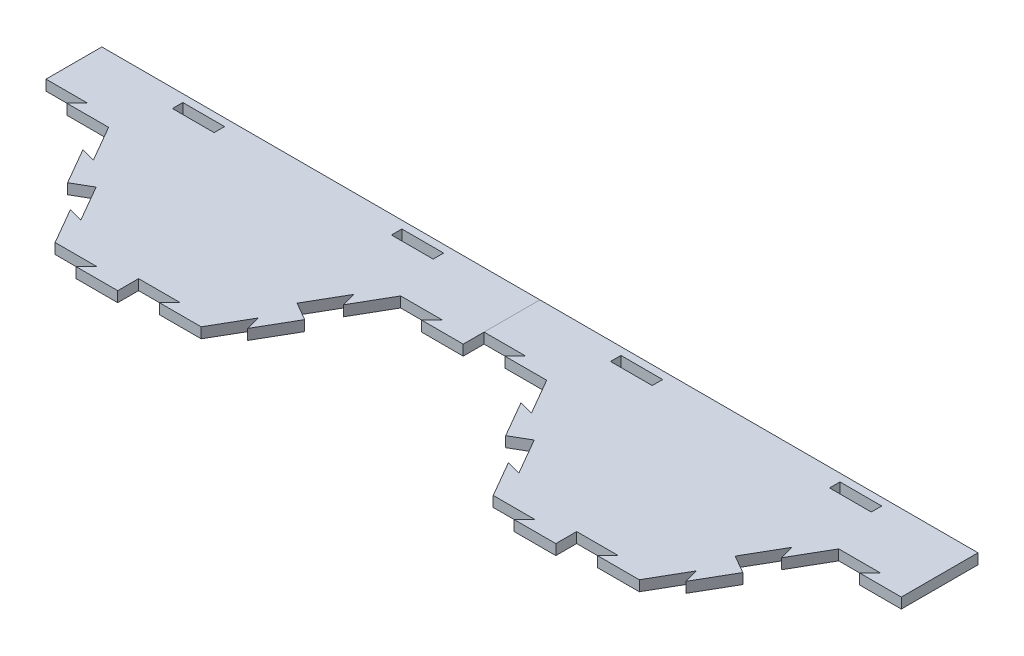
from build123d import *

# Parameters (mm, degrees)
BOSS_EXTRUDE1_DEPTH = 6.35
CUT_EXTRUDE4_DEPTH  = 7.35
BOSS_EXTRUDE4_DEPTH = 6.35
CIRPATTERN7_COUNT   = 6
SKETCH12_W          = 177.8
SKETCH12_H          = 83.339658396
CUT_EXTRUDE5_DEPTH  = 7.35
SKETCH13_W          = 266.7
SKETCH13_H          = 6.35
BOSS_EXTRUDE5_DEPTH = 40.327916296
CUT_EXTRUDE6_DEPTH  = 7.35
BOSS_EXTRUDE6_DEPTH = 6.35
SKETCH17_W          = 25.4
SKETCH17_H          = 6.35
CUT_EXTRUDE8_DEPTH  = 7.35
LPATTERN1_COUNT     = 2
LPATTERN1_PITCH     = 266.7


with BuildPart() as part:
    # Sketch1 → Boss-Extrude1 (new body)
    with BuildSketch(Plane(origin=(0, 0, 0), x_dir=(1, 0, 0), z_dir=(0, 1, 0))):
        Polygon((88.9, 0), (44.45, 76.989658396), (-44.45, 76.989658396), (-88.9, 0), (-44.45, -76.989658396), (44.45, -76.989658396), align=None)
    extrude(amount=-BOSS_EXTRUDE1_DEPTH)

    # Sketch10 → Cut-Extrude4 (cut, through all)
    with BuildSketch(Plane(origin=(0, 0, 0), x_dir=(1, 0, 0), z_dir=(0, 1, 0))):
        Polygon((57.15, 54.99261314), (48.475738686, 57.316874454), (61.175738686, 35.319829198), (66.675, 38.494829198), align=None)
    cut_extrude4 = extrude(amount=-CUT_EXTRUDE4_DEPTH, mode=Mode.SUBTRACT)

    # Sketch11 → Boss-Extrude4 (add)
    with BuildSketch(Plane(origin=(0, 0, 0), x_dir=(1, 0, 0), z_dir=(0, 1, 0))):
        Polygon((66.675, 38.494829198), (72.174261314, 41.669829198), (84.874261314, 19.672783942), (76.2, 21.997045256), align=None)
    boss_extrude4 = extrude(amount=-BOSS_EXTRUDE4_DEPTH)

    # CirPattern7: Cut-Extrude4, Boss-Extrude4 ×6 about axis
    cirpattern7_axis = Axis((0, 0, 0), (0, 1, 0))
    for i in range(1, CIRPATTERN7_COUNT):
        add(cut_extrude4.rotate(cirpattern7_axis, i * 360 / CIRPATTERN7_COUNT), mode=Mode.SUBTRACT)
        add(boss_extrude4.rotate(cirpattern7_axis, i * 360 / CIRPATTERN7_COUNT))

    # Sketch12 → Cut-Extrude5 (cut, through all)
    with BuildSketch(Plane(origin=(0, 0, 0), x_dir=(1, 0, 0), z_dir=(0, 1, 0))):
        with Locations((0, 41.669829198)):
            Rectangle(SKETCH12_W, SKETCH12_H)
    extrude(amount=-CUT_EXTRUDE5_DEPTH, mode=Mode.SUBTRACT)

    # Sketch13 → Boss-Extrude5 (add)
    with BuildSketch(Plane(origin=(0, 0, 0), x_dir=(-1, 0, 0), z_dir=(0, 0, -1))):
        with Locations((0, -3.175)):
            Rectangle(SKETCH13_W, SKETCH13_H)
    extrude(amount=BOSS_EXTRUDE5_DEPTH)

    # Sketch15 → Cut-Extrude6 (cut, through all)
    with BuildSketch(Plane(origin=(0, 0, 0), x_dir=(1, 0, 0), z_dir=(0, 1, 0))):
        Polygon((-114.3, 0), (-107.95, 6.35), (-133.35, 6.35), (-133.35, 0), align=None)
    extrude(amount=-CUT_EXTRUDE6_DEPTH, mode=Mode.SUBTRACT)

    # Sketch16 → Boss-Extrude6 (add)
    with BuildSketch(Plane(origin=(0, 0, 0), x_dir=(1, 0, 0), z_dir=(0, 1, 0))):
        Polygon((114.3, 0), (107.95, -6.35), (133.35, -6.35), (133.35, 0), align=None)
    extrude(amount=-BOSS_EXTRUDE6_DEPTH)

    # Sketch17 → Cut-Extrude8 (cut, through all)
    with BuildSketch(Plane(origin=(0, 0, 0), x_dir=(1, 0, 0), z_dir=(0, 1, 0))):
        with Locations((-66.675, 32.504390033)):
            Rectangle(SKETCH17_W, SKETCH17_H)
        with Locations((66.675, 32.504390033)):
            Rectangle(SKETCH17_W, SKETCH17_H)
    extrude(amount=-CUT_EXTRUDE8_DEPTH, mode=Mode.SUBTRACT)


with BuildPart() as lpattern1_1:
    # LPattern1: pattern copy
    add(part.part.moved(Location(Vector(1, 0, 0) * (1 * LPATTERN1_PITCH))))


solid = Compound([part.part, lpattern1_1.part])
